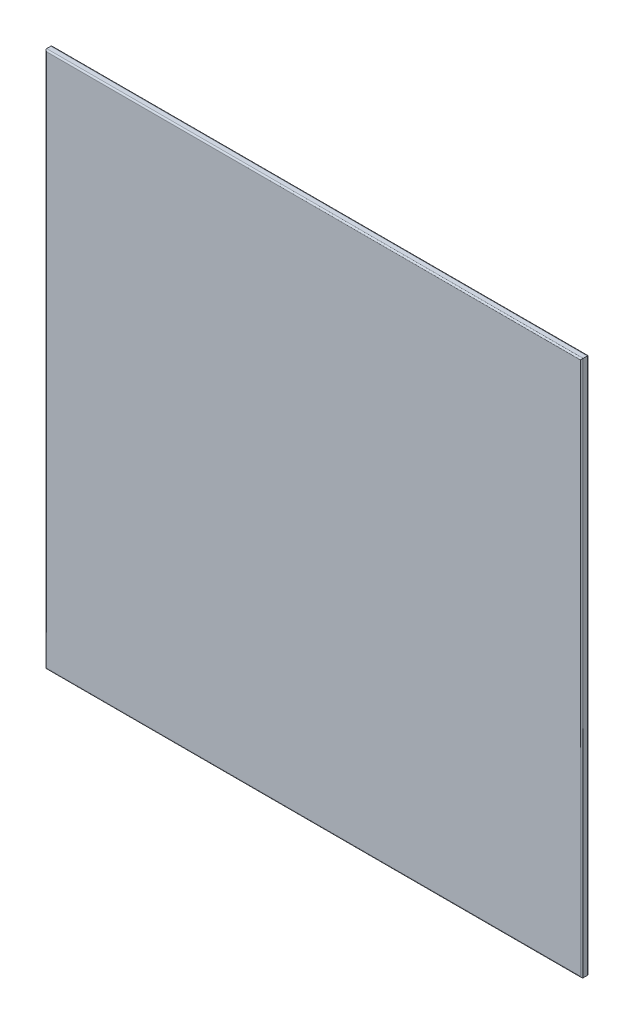
from build123d import *

# Parameters (mm, degrees)
SKETCH1_W           = 1140
SKETCH1_H           = 1140
BOSS_EXTRUDE1_DEPTH = 15
FILLET1_R           = 3


with BuildPart() as part:
    # Sketch1 → Boss-Extrude1 (new body)
    with BuildSketch(Plane.XY):
        with Locations((575, 575)):
            Rectangle(SKETCH1_W, SKETCH1_H)
    extrude(amount=BOSS_EXTRUDE1_DEPTH)

    # Fillet1
    fillet1_edges = [part.edges().sort_by_distance(p)[0] for p in [
        (1145, 575, 15),
        (575, 1145, 15),
        (5, 575, 15),
        (575, 1145, 0),
        (1145, 575, 0),
        (575, 5, 0),
        (5, 575, 0),
        (575, 5, 15),
    ]]
    fillet(fillet1_edges, radius=FILLET1_R)


solid = part.part
